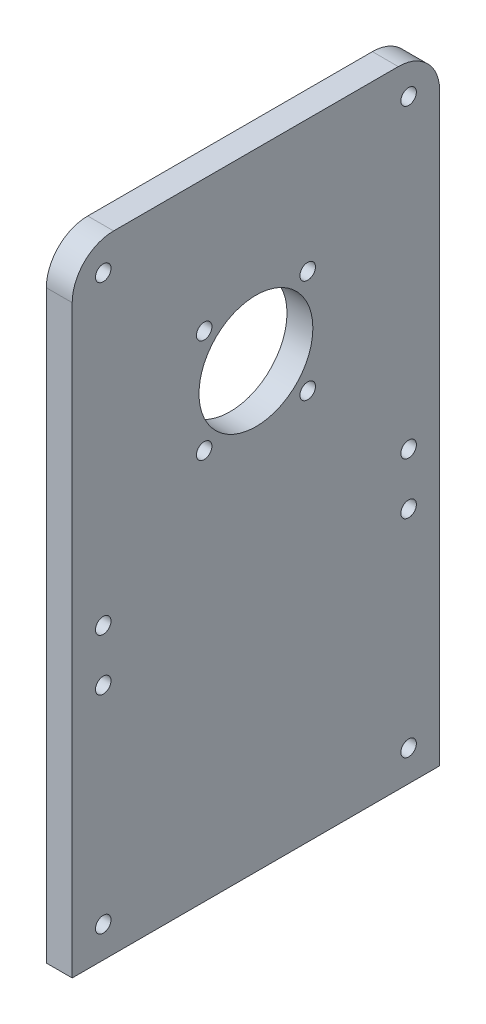
from build123d import *

# Parameters (mm, degrees)
SKETCH1_W           = 71
SKETCH1_H           = 121
SKETCH1_R           = 1.5
SKETCH1_R_2         = 11
BOSS_EXTRUDE1_DEPTH = 5
FILLET1_R           = 8


with BuildPart() as part:
    # Sketch1 → Boss-Extrude1 (new body)
    with BuildSketch(Plane(origin=(0, 0, 0), x_dir=(0, 0, -1), z_dir=(1, 0, 0))):
        with Locations((35.5, 60.5)):
            Rectangle(SKETCH1_W, SKETCH1_H)
        with Locations((6, 115)):
            Circle(SKETCH1_R, mode=Mode.SUBTRACT)
        with Locations((65, 115)):
            Circle(SKETCH1_R, mode=Mode.SUBTRACT)
        with Locations((35.5, 85.5)):
            Circle(SKETCH1_R_2, mode=Mode.SUBTRACT)
        with Locations((25.5, 95.5)):
            Circle(SKETCH1_R, mode=Mode.SUBTRACT)
        with Locations((45.5, 95.5)):
            Circle(SKETCH1_R, mode=Mode.SUBTRACT)
        with Locations((45.5, 75.5)):
            Circle(SKETCH1_R, mode=Mode.SUBTRACT)
        with Locations((25.5, 75.5)):
            Circle(SKETCH1_R, mode=Mode.SUBTRACT)
        with Locations((6, 56)):
            Circle(SKETCH1_R, mode=Mode.SUBTRACT)
        with Locations((65, 56)):
            Circle(SKETCH1_R, mode=Mode.SUBTRACT)
        with Locations((6, 6)):
            Circle(SKETCH1_R, mode=Mode.SUBTRACT)
        with Locations((65, 6)):
            Circle(SKETCH1_R, mode=Mode.SUBTRACT)
        with Locations((6, 46)):
            Circle(SKETCH1_R, mode=Mode.SUBTRACT)
        with Locations((65, 46)):
            Circle(SKETCH1_R, mode=Mode.SUBTRACT)
    extrude(amount=BOSS_EXTRUDE1_DEPTH)

    # Fillet1
    fillet1_edges = [part.edges().sort_by_distance(p)[0] for p in [
        (2.5, 121, 0),
        (2.5, 121, -71),
    ]]
    fillet(fillet1_edges, radius=FILLET1_R)


solid = part.part
